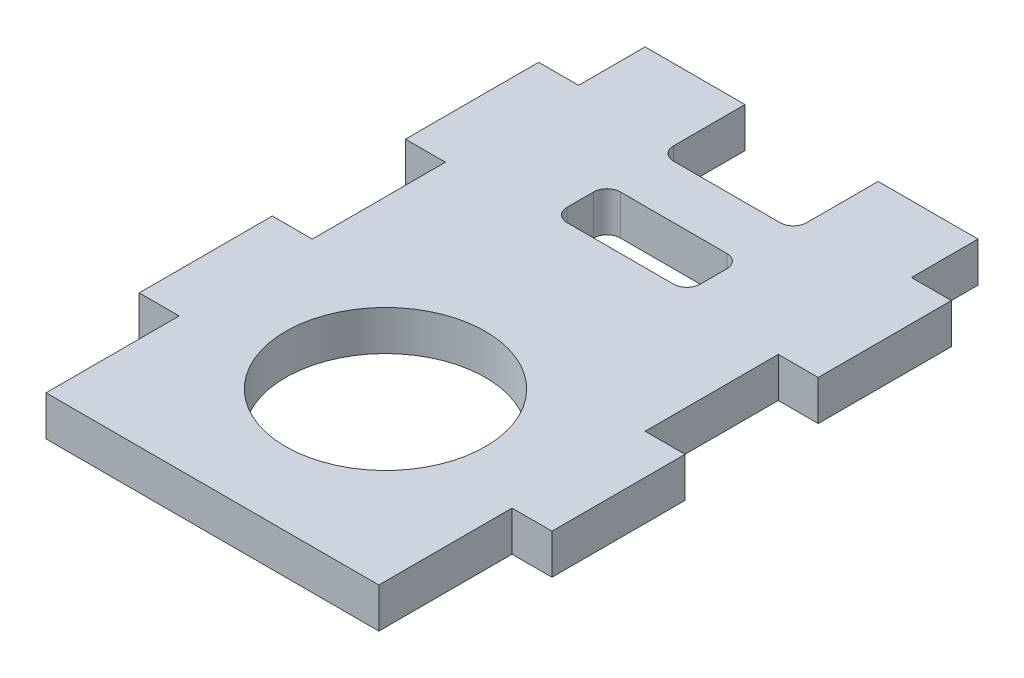
from build123d import *

# Parameters (mm, degrees)
SKETCH1_W           = 25
SKETCH1_H           = 45
BOSS_EXTRUDE1_DEPTH = 3
SKETCH2_R           = 7.5
SKETCH2_W           = 10
SKETCH2_H           = 6.365
SKETCH2_H_2         = 4
CUT_EXTRUDE1_DEPTH  = 4
FILLET1_R           = 1
SKETCH3_W           = 3
SKETCH3_H           = 10
BOSS_EXTRUDE2_DEPTH = 3


with BuildPart() as part:
    # Sketch1 → Boss-Extrude1 (new body)
    with BuildSketch(Plane(origin=(0, 0, 0), x_dir=(1, 0, 0), z_dir=(0, 1, 0))):
        Rectangle(SKETCH1_W, SKETCH1_H)
    extrude(amount=BOSS_EXTRUDE1_DEPTH)

    # Sketch2 → Cut-Extrude1 (cut, through all)
    with BuildSketch(Plane(origin=(0, 3, 0), x_dir=(1, 0, 0), z_dir=(0, 1, 0))):
        with Locations((0, -9.5)):
            Circle(SKETCH2_R)
        with Locations((0, 19.3175)):
            Rectangle(SKETCH2_W, SKETCH2_H)
        with Locations((0, 10.135)):
            Rectangle(SKETCH2_W, SKETCH2_H_2)
    extrude(amount=-CUT_EXTRUDE1_DEPTH, mode=Mode.SUBTRACT)

    # Fillet1
    fillet1_edges = [part.edges().sort_by_distance(p)[0] for p in [
        (-5, 1.5, -16.135),
        (5, 1.5, -16.135),
        (-5, 1.5, -8.135),
        (-5, 1.5, -12.135),
        (5, 1.5, -12.135),
        (5, 1.5, -8.135),
    ]]
    fillet(fillet1_edges, radius=FILLET1_R)

    # Sketch3 → Boss-Extrude2 (add)
    with BuildSketch(Plane(origin=(0, 3, 0), x_dir=(1, 0, 0), z_dir=(0, 1, 0))):
        with Locations((14, -7.5)):
            Rectangle(SKETCH3_W, SKETCH3_H)
        with Locations((14, 12.5)):
            Rectangle(SKETCH3_W, SKETCH3_H)
        with Locations((-14, -7.5)):
            Rectangle(SKETCH3_W, SKETCH3_H)
        with Locations((-14, 12.5)):
            Rectangle(SKETCH3_W, SKETCH3_H)
    extrude(amount=-BOSS_EXTRUDE2_DEPTH)


solid = part.part
